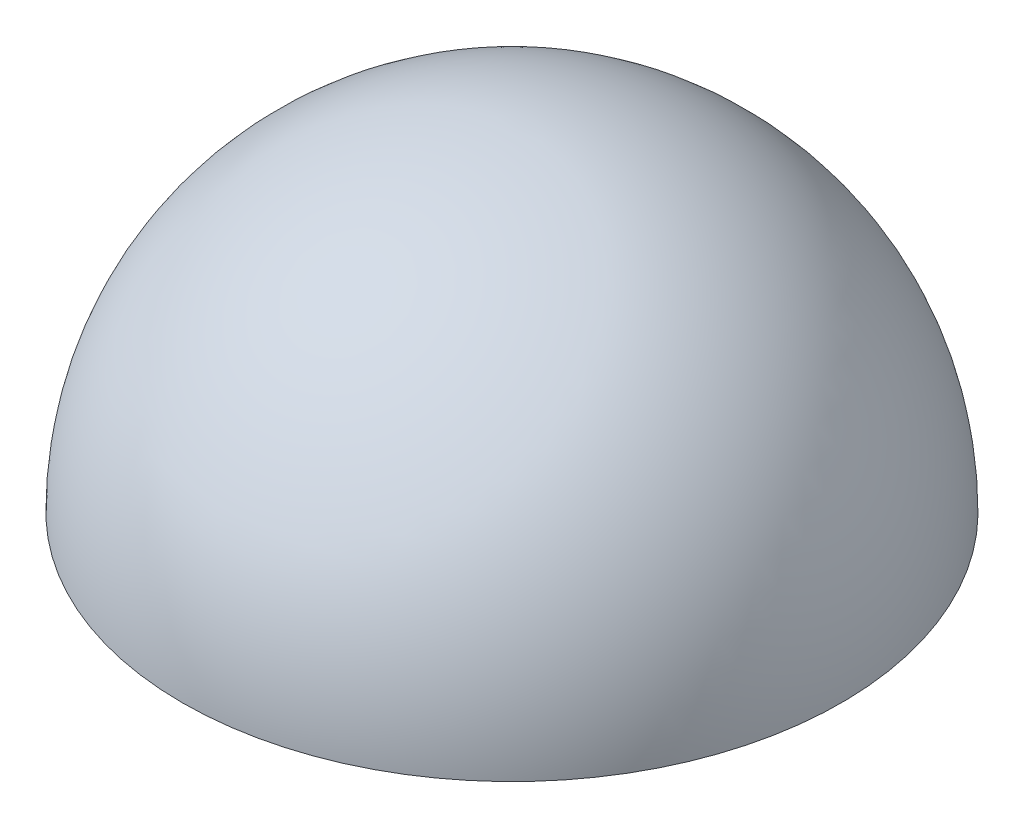
from build123d import *

# Parameters (mm, degrees)
ROTATION1_ANGLE = 180


with BuildPart() as part:
    # Skizze1 → Rotation1 (revolve)
    with BuildSketch(Plane(origin=(0, 0, 0), x_dir=(1, 0, 0), z_dir=(0, 1, 0))):
        with BuildLine():
            Line((0, 12.5), (0, 7.5))
            ThreePointArc((0, 7.5), (7.5, 0), (0, -7.5))
            Line((0, -7.5), (0, -12.5))
            ThreePointArc((0, -12.5), (12.5, 0), (0, 12.5))
        make_face()
    revolve(axis=Axis((0, 0, -16.072896091), (0, 0, 1)), revolution_arc=ROTATION1_ANGLE)


solid = part.part
